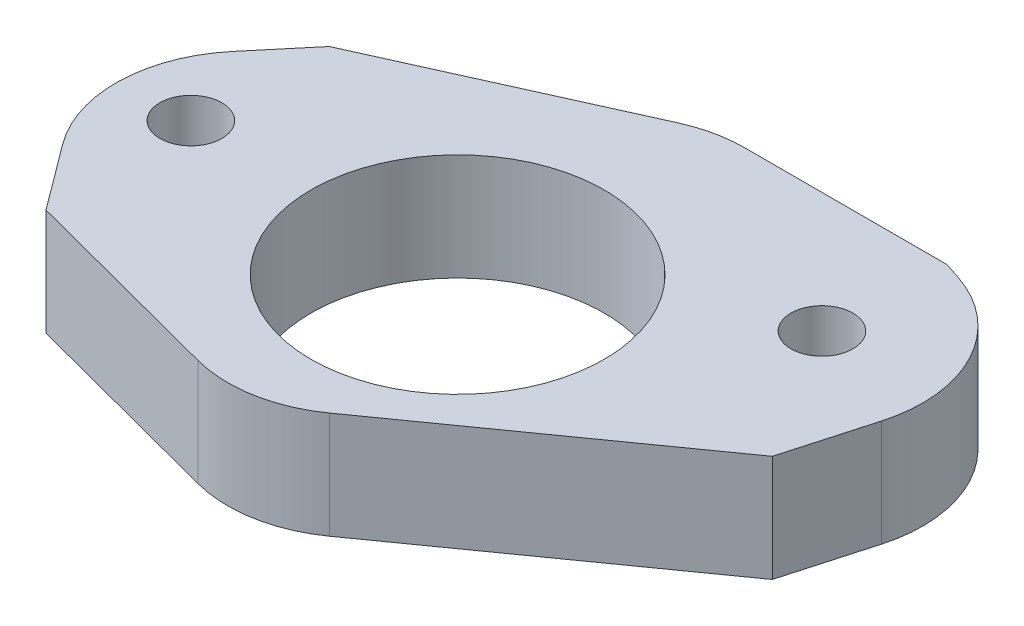
from build123d import *

# Parameters (mm, degrees)
SKETCH1_R           = 5.5
SKETCH1_R_2         = 1.16205649
BOSS_EXTRUDE1_DEPTH = 4
FILLET1_R           = 5


with BuildPart() as part:
    # Sketch1 → Boss-Extrude1 (new body)
    with BuildSketch(Plane(origin=(0, 0, 0), x_dir=(1, 0, 0), z_dir=(0, 1, 0))):
        Polygon((-9.811758465, -5.619740701), (0.188241535, -8.249999209), (11.79974155, 0), (14, 7.8), (8.848495573, 9.5), (0.188241535, 9.5), (-9.811758465, 5), (-14, 0), align=None)
        Circle(SKETCH1_R, mode=Mode.SUBTRACT)
        with Locations((-10, 0)):
            Circle(SKETCH1_R_2, mode=Mode.SUBTRACT)
        with Locations((8.660254038, 5)):
            Circle(SKETCH1_R_2, mode=Mode.SUBTRACT)
    extrude(amount=BOSS_EXTRUDE1_DEPTH)

    # Fillet1
    fillet1_edges = [part.edges().sort_by_distance(p)[0] for p in [
        (-14, 2, 0),
        (0.188241535, 2, -9.5),
        (14, 2, -7.8),
        (0.188241535, 2, 8.249999209),
    ]]
    fillet(fillet1_edges, radius=FILLET1_R)


solid = part.part
